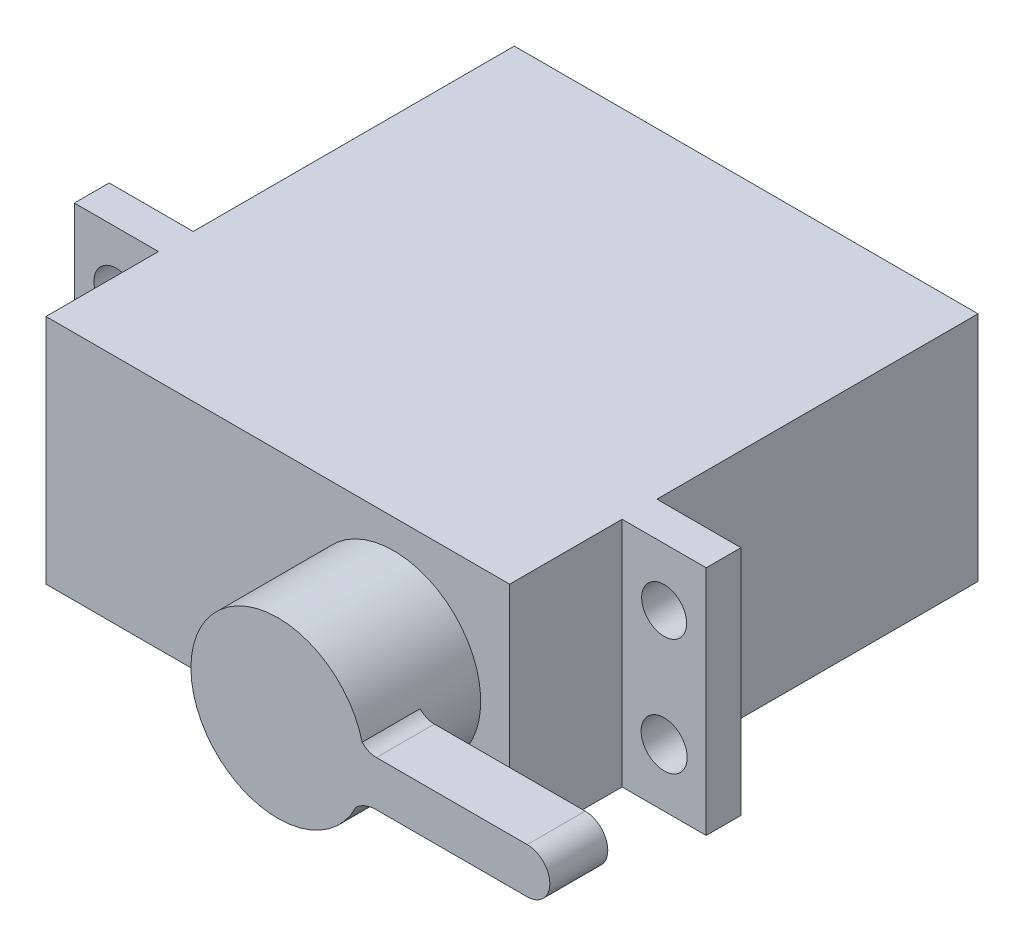
from build123d import *

# Parameters (mm, degrees)
SKETCH1_W           = 40
SKETCH1_H           = 40.4
BOSS_EXTRUDE1_DEPTH = 20
SKETCH3_W           = 3
SKETCH3_H           = 20
BOSS_EXTRUDE2_DEPTH = 7.25
SKETCH5_R           = 1.938887877
SKETCH5_R_2         = 1.98650292
CUT_EXTRUDE1_DEPTH  = 7.25
SKETCH6_R           = 7.5
BOSS_EXTRUDE3_DEPTH = 10
BOSS_EXTRUDE4_DEPTH = 5


with BuildPart() as part:
    # Sketch1 → Boss-Extrude1 (new body)
    with BuildSketch(Plane(origin=(0, 0, 0), x_dir=(1, 0, 0), z_dir=(0, 1, 0))):
        with Locations((-7.684478372, -4.939949109)):
            Rectangle(SKETCH1_W, SKETCH1_H)
    extrude(amount=BOSS_EXTRUDE1_DEPTH)

    # Sketch3 → Boss-Extrude2 (add)
    with BuildSketch(Plane(origin=(12.315521628, 0, 0), x_dir=(0, 0, -1), z_dir=(1, 0, 0))):
        with Locations((-13.939949109, 10)):
            Rectangle(SKETCH3_W, SKETCH3_H)
    boss_extrude2 = extrude(amount=BOSS_EXTRUDE2_DEPTH)

    # Mirror1: Boss-Extrude2 across plane
    add(boss_extrude2.mirror(Plane.ZY.offset(7.684478372)))

    # Sketch5 → Cut-Extrude1 (cut)
    with BuildSketch(Plane.XY.offset(15.439949109)):
        with Locations((15.940521628, 15)):
            Circle(SKETCH5_R)
        with Locations((15.940521628, 5)):
            Circle(SKETCH5_R_2)
    cut_extrude1 = extrude(amount=-CUT_EXTRUDE1_DEPTH, mode=Mode.SUBTRACT)

    # Mirror2: Cut-Extrude1 across plane
    add(cut_extrude1.mirror(Plane.ZY.offset(7.684478372)), mode=Mode.SUBTRACT)

    # Sketch6 → Boss-Extrude3 (add)
    with BuildSketch(Plane.XY.offset(25.139949109)):
        with Locations((2.315521628, 10)):
            Circle(SKETCH6_R)
    extrude(amount=BOSS_EXTRUDE3_DEPTH)

    # Sketch8 → Boss-Extrude4 (add)
    with BuildSketch(Plane.XY.offset(35.139949109)):
        with BuildLine():
            Line((10.818468117, 7.39802315), (23.828352366, 7.39802315))
            ThreePointArc((23.828352366, 7.39802315), (25.779835003, 9.349505788), (23.828352366, 11.300988425))
            Line((23.828352366, 11.300988425), (10.818468117, 11.300988425))
            ThreePointArc((10.818468117, 11.300988425), (9.571889646, 11.847462314), (9.129094063, 13.1345224))
            ThreePointArc((9.129094063, 13.1345224), (-5.184055447, 10.07964725), (9.060986037, 6.72147748))
            ThreePointArc((9.060986037, 6.72147748), (9.876866117, 7.223046033), (10.818468117, 7.39802315))
        make_face()
    extrude(amount=-BOSS_EXTRUDE4_DEPTH)


solid = part.part
